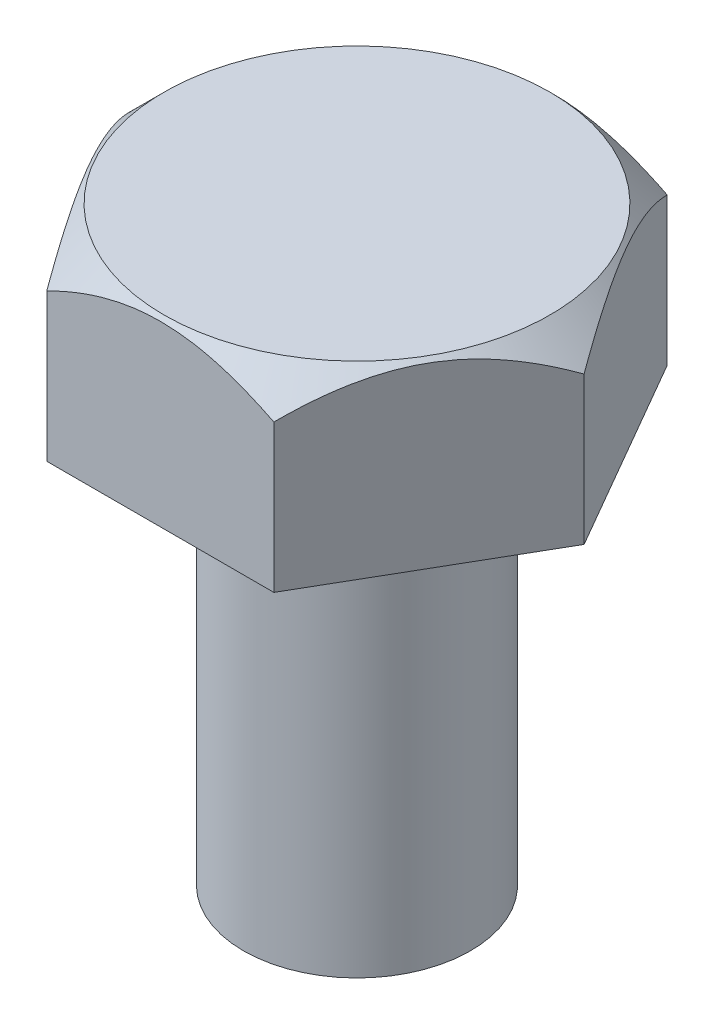
from build123d import *

# Parameters (mm, degrees)
SKETCH1_R           = 2.5
BOSS_EXTRUDE1_DEPTH = 9
BOSS_EXTRUDE4_DEPTH = 4
SKETCH5_OUTSIDE_W   = 23.71
SKETCH5_OUTSIDE_H   = 22.37
SKETCH5_OUTSIDE_R   = 4.25
CUT_EXTRUDE1_DEPTH  = 4
CUT_EXTRUDE1_TAPER  = 45


with BuildPart() as part:
    # Sketch1 → Boss-Extrude1 (new body)
    with BuildSketch(Plane(origin=(0, 0, 0), x_dir=(1, 0, 0), z_dir=(0, 1, 0))):
        Circle(SKETCH1_R)
    extrude(amount=BOSS_EXTRUDE1_DEPTH)

    # Sketch3 → Boss-Extrude4 (add)
    with BuildSketch(Plane(origin=(0, 9, 0), x_dir=(1, 0, 0), z_dir=(0, 1, 0))):
        Polygon((5, 0), (2.5, 4.330127019), (-2.5, 4.330127019), (-5, 0), (-2.5, -4.330127019), (2.5, -4.330127019), align=None)
    extrude(amount=BOSS_EXTRUDE4_DEPTH)

    # Sketch5 outside → Cut-Extrude1 (cut)
    with BuildSketch(Plane(origin=(0, 13, 0), x_dir=(1, 0, 0), z_dir=(0, 1, 0))):
        Rectangle(SKETCH5_OUTSIDE_W, SKETCH5_OUTSIDE_H)
        Circle(SKETCH5_OUTSIDE_R, mode=Mode.SUBTRACT)
    extrude(amount=-CUT_EXTRUDE1_DEPTH, taper=CUT_EXTRUDE1_TAPER, mode=Mode.SUBTRACT)


solid = part.part
